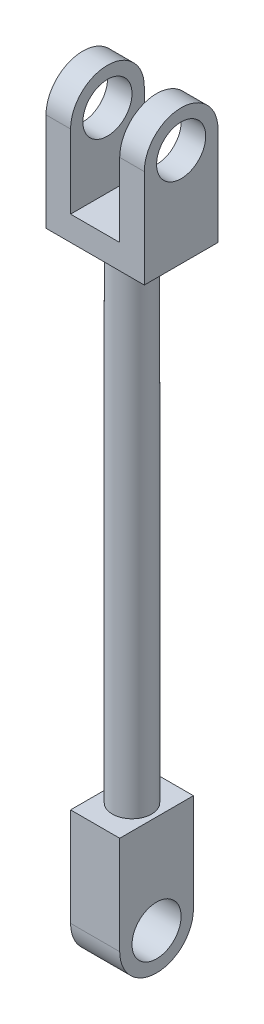
from build123d import *

# Parameters (mm, degrees)
SKETCH1_R           = 4
BOSS_EXTRUDE1_DEPTH = 50
BOSS_EXTRUDE2_DEPTH = 10
SKETCH3_R           = 5
CUT_EXTRUDE1_DEPTH  = 21
SKETCH4_W           = 10
SKETCH4_H           = 22.5
CUT_EXTRUDE2_DEPTH  = 16
BOSS_EXTRUDE3_DEPTH = 5
SKETCH6_R           = 5
CUT_EXTRUDE3_DEPTH  = 20


with BuildPart() as part:
    # Sketch1 → Boss-Extrude1 (new body, symmetric)
    with BuildSketch(Plane(origin=(0, 0, 0), x_dir=(1, 0, 0), z_dir=(0, 1, 0))):
        Circle(SKETCH1_R)
    extrude(amount=BOSS_EXTRUDE1_DEPTH, both=True)

    # Sketch2 → Boss-Extrude2 (add, symmetric)
    with BuildSketch(Plane(origin=(0, 0, 0), x_dir=(0, 0, -1), z_dir=(1, 0, 0))):
        with BuildLine():
            Line((0, 50), (7.5, 50))
            Line((7.5, 50), (7.5, 70))
            ThreePointArc((7.5, 70), (0, 77.5), (-7.5, 70))
            Line((-7.5, 70), (-7.5, 50))
            Line((-7.5, 50), (0, 50))
        make_face()
    extrude(amount=BOSS_EXTRUDE2_DEPTH, both=True)

    # Sketch3 → Cut-Extrude1 (cut, through all)
    with BuildSketch(Plane(origin=(10, 0, 0), x_dir=(0, 0, -1), z_dir=(1, 0, 0))):
        with Locations((0, 70)):
            Circle(SKETCH3_R)
    extrude(amount=-CUT_EXTRUDE1_DEPTH, mode=Mode.SUBTRACT)

    # Sketch4 → Cut-Extrude2 (cut, through all)
    with BuildSketch(Plane.XY.offset(7.5)):
        with Locations((0, 66.25)):
            Rectangle(SKETCH4_W, SKETCH4_H)
    extrude(amount=-CUT_EXTRUDE2_DEPTH, mode=Mode.SUBTRACT)

    # Sketch5 → Boss-Extrude3 (add, symmetric)
    with BuildSketch(Plane(origin=(0, 0, 0), x_dir=(0, 0, -1), z_dir=(1, 0, 0))):
        with BuildLine():
            Line((-7.5, -50), (7.5, -50))
            Line((7.5, -50), (7.5, -70))
            ThreePointArc((7.5, -70), (0, -77.5), (-7.5, -70))
            Line((-7.5, -70), (-7.5, -50))
        make_face()
    extrude(amount=BOSS_EXTRUDE3_DEPTH, both=True)

    # Sketch6 → Cut-Extrude3 (cut)
    with BuildSketch(Plane(origin=(5, 0, 0), x_dir=(0, 0, -1), z_dir=(1, 0, 0))):
        with Locations((0, -70)):
            Circle(SKETCH6_R)
    extrude(amount=-CUT_EXTRUDE3_DEPTH, mode=Mode.SUBTRACT)


solid = part.part
